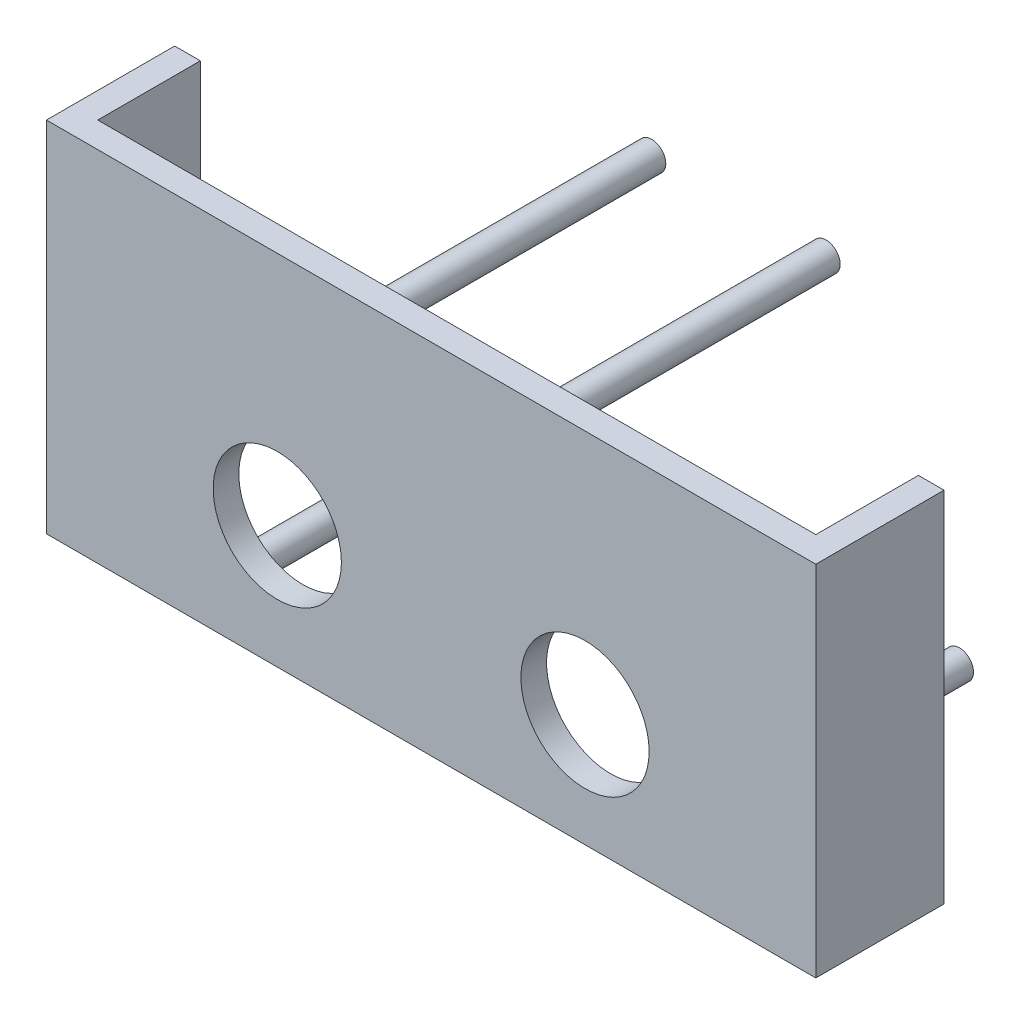
from build123d import *

# Parameters (mm, degrees)
ESQUISSE1_W             = 100
ESQUISSE1_H             = 69.87
BOSS_EXTRU_1_DEPTH      = 5
ESQUISSE2_R             = 12.5
ENL_V_MAT_EXTRU_1_DEPTH = 5
ESQUISSE3_W             = 25
ESQUISSE3_H             = 69.87
BOSS_EXTRU_2_DEPTH      = 5
ESQUISSE4_W             = 5
ESQUISSE4_H             = 69.87
BOSS_EXTRU_3_DEPTH      = 20
ESQUISSE2_3_R           = 2.75
BOSS_EXTRU_4_DEPTH      = 60
ESQUISSE2_4_R           = 2.75
BOSS_EXTRU_5_DEPTH      = 60
ESQUISSE2_5_R           = 2.75
BOSS_EXTRU_6_DEPTH      = 60
ESQUISSE2_6_R           = 2.75
BOSS_EXTRU_7_DEPTH      = 60


with BuildPart() as part:
    # Esquisse1 → Boss.-Extru.1 (new body)
    with BuildSketch(Plane.XY):
        with Locations((-50, 34.935)):
            Rectangle(ESQUISSE1_W, ESQUISSE1_H)
    extrude(amount=BOSS_EXTRU_1_DEPTH)

    # Esquisse2 → Enlèv. mat.-Extru.1 (cut)
    with BuildSketch(Plane.XY.offset(5)):
        with Locations((-80, 23.913092396)):
            Circle(ESQUISSE2_R)
        with Locations((-20, 21.980812212)):
            Circle(ESQUISSE2_R)
    extrude(amount=-ENL_V_MAT_EXTRU_1_DEPTH, mode=Mode.SUBTRACT)

    # Esquisse3 → Boss.-Extru.2 (add)
    with BuildSketch(Plane.XY.offset(5)):
        with Locations((-112.5, 34.935)):
            Rectangle(ESQUISSE3_W, ESQUISSE3_H)
        with Locations((12.5, 34.935)):
            Rectangle(ESQUISSE3_W, ESQUISSE3_H)
    extrude(amount=-BOSS_EXTRU_2_DEPTH)

    # Esquisse4 → Boss.-Extru.3 (add)
    with BuildSketch(Plane(origin=(0, 0, 0), x_dir=(-1, 0, 0), z_dir=(0, 0, -1))):
        with Locations((122.5, 34.935)):
            Rectangle(ESQUISSE4_W, ESQUISSE4_H)
        with Locations((-22.5, 34.935)):
            Rectangle(ESQUISSE4_W, ESQUISSE4_H)
    extrude(amount=BOSS_EXTRU_3_DEPTH)

    # Esquisse2_3 → Boss.-Extru.4 (add)
    with BuildSketch(Plane.XY.offset(5)):
        with Locations((-67, 62.87)):
            Circle(ESQUISSE2_3_R)
    extrude(amount=-BOSS_EXTRU_4_DEPTH)

    # Esquisse2_4 → Boss.-Extru.5 (add)
    with BuildSketch(Plane.XY.offset(5)):
        with Locations((-33, 62.87)):
            Circle(ESQUISSE2_4_R)
    extrude(amount=-BOSS_EXTRU_5_DEPTH)

    # Esquisse2_5 → Boss.-Extru.6 (add)
    with BuildSketch(Plane.XY.offset(5)):
        with Locations((-93, 7)):
            Circle(ESQUISSE2_5_R)
    extrude(amount=-BOSS_EXTRU_6_DEPTH)

    # Esquisse2_6 → Boss.-Extru.7 (add)
    with BuildSketch(Plane.XY.offset(5)):
        with Locations((-7, 7)):
            Circle(ESQUISSE2_6_R)
    extrude(amount=-BOSS_EXTRU_7_DEPTH)


solid = part.part
